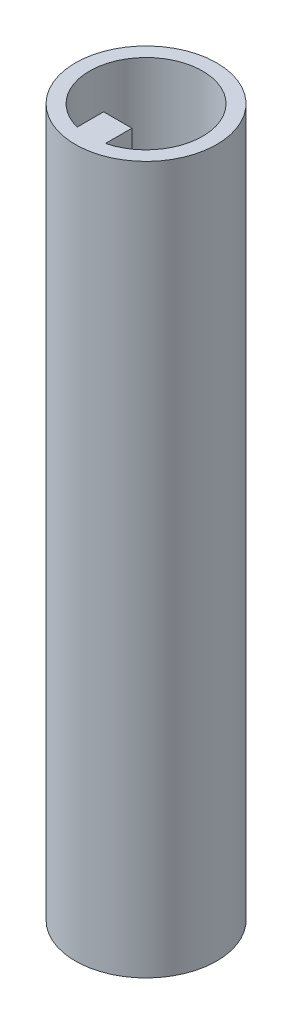
from build123d import *

# Parameters (mm, degrees)
CROQUIS1_R              = 10
SALIENTE_EXTRUIR1_DEPTH = 100
CROQUIS2_R              = 10
CROQUIS2_R_2            = 2.75
SALIENTE_EXTRUIR2_DEPTH = 3
CROQUIS3_R              = 0.9
CORTAR_EXTRUIR1_DEPTH   = 10


with BuildPart() as part:
    # Croquis1 → Saliente-Extruir1 (new body)
    with BuildSketch(Plane.XZ.offset(56.611885127)):
        with Locations((-3.039414363, 30.619510909)):
            Circle(CROQUIS1_R)
        with BuildLine():
            Line((-1.039414363, 38.365477601), (-1.039414363, 34.619510909))
            Line((-1.039414363, 34.619510909), (-5.039414363, 34.619510909))
            Line((-5.039414363, 34.619510909), (-5.039414363, 38.365477601))
            ThreePointArc((-5.039414363, 38.365477601), (-3.039414363, 22.619510909), (-1.039414363, 38.365477601))
        make_face(mode=Mode.SUBTRACT)
    extrude(amount=SALIENTE_EXTRUIR1_DEPTH)

    # Croquis2 → Saliente-Extruir2 (add)
    with BuildSketch(Plane.XZ.offset(156.611885127)):
        with Locations((-3.039414363, 30.619510909)):
            Circle(CROQUIS2_R)
        with Locations((-3.039414363, 30.619510909)):
            Circle(CROQUIS2_R_2, mode=Mode.SUBTRACT)
    extrude(amount=-SALIENTE_EXTRUIR2_DEPTH)

    # Croquis3 → Cortar-Extruir1 (cut)
    with BuildSketch(Plane.XZ.offset(156.611885127)):
        with Locations((-3.039414363, 37.577400418)):
            Circle(CROQUIS3_R)
        with Locations((3.918475146, 30.619510909)):
            Circle(CROQUIS3_R)
        with Locations((-3.039414363, 23.6616214)):
            Circle(CROQUIS3_R)
        with Locations((-9.997303872, 30.619510909)):
            Circle(CROQUIS3_R)
    extrude(amount=-CORTAR_EXTRUIR1_DEPTH, mode=Mode.SUBTRACT)


solid = part.part
